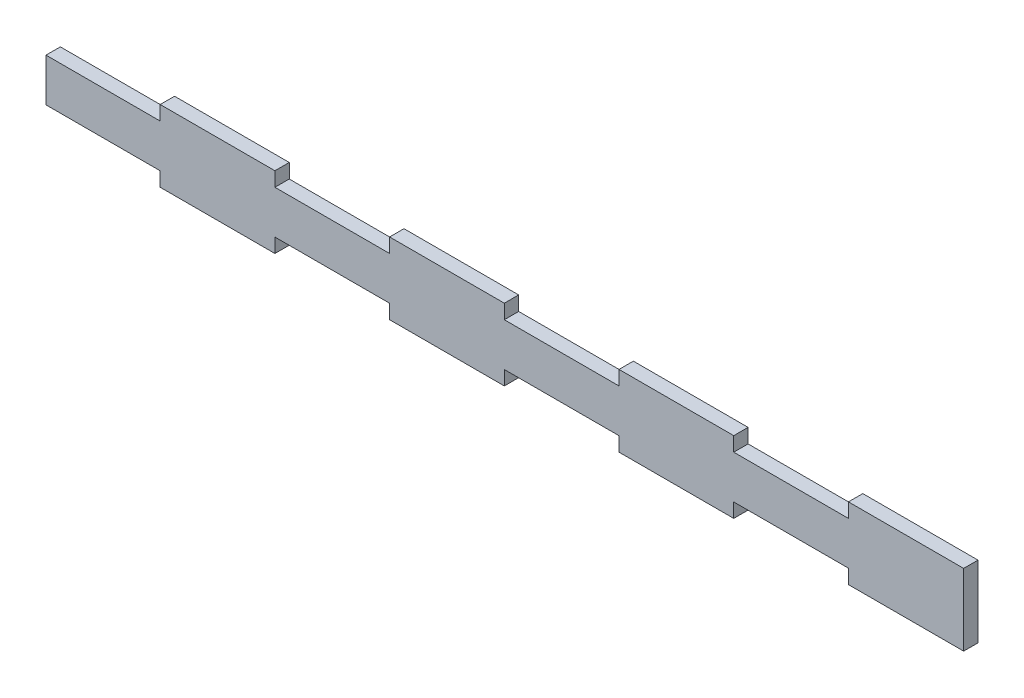
from build123d import *

# Parameters (mm, degrees)
SKETCH1_W           = 203.2
SKETCH1_H           = 15.875
BOSS_EXTRUDE1_DEPTH = 3.175
SKETCH2_W           = 25.4
SKETCH2_H           = 3.175
CUT_EXTRUDE1_DEPTH  = 3.175


with BuildPart() as part:
    # Sketch1 → Boss-Extrude1 (new body)
    with BuildSketch(Plane.XY):
        with Locations((0.111004585, 0.008672233)):
            Rectangle(SKETCH1_W, SKETCH1_H)
    extrude(amount=BOSS_EXTRUDE1_DEPTH)

    # Sketch2 → Cut-Extrude1 (cut)
    with BuildSketch(Plane.XY.offset(3.175)):
        with Locations((-38.1, 6.358672233)):
            Rectangle(SKETCH2_W, SKETCH2_H)
        with Locations((-88.9, 6.358672233)):
            Rectangle(SKETCH2_W, SKETCH2_H)
        with Locations((12.7, 6.358672233)):
            Rectangle(SKETCH2_W, SKETCH2_H)
        with Locations((63.5, 6.358672233)):
            Rectangle(SKETCH2_W, SKETCH2_H)
        with Locations((63.5, -6.358672233)):
            Rectangle(SKETCH2_W, SKETCH2_H)
        with Locations((12.7, -6.358672233)):
            Rectangle(SKETCH2_W, SKETCH2_H)
        with Locations((-38.1, -6.358672233)):
            Rectangle(SKETCH2_W, SKETCH2_H)
        with Locations((-88.9, -6.358672233)):
            Rectangle(SKETCH2_W, SKETCH2_H)
    extrude(amount=-CUT_EXTRUDE1_DEPTH, mode=Mode.SUBTRACT)


solid = part.part
